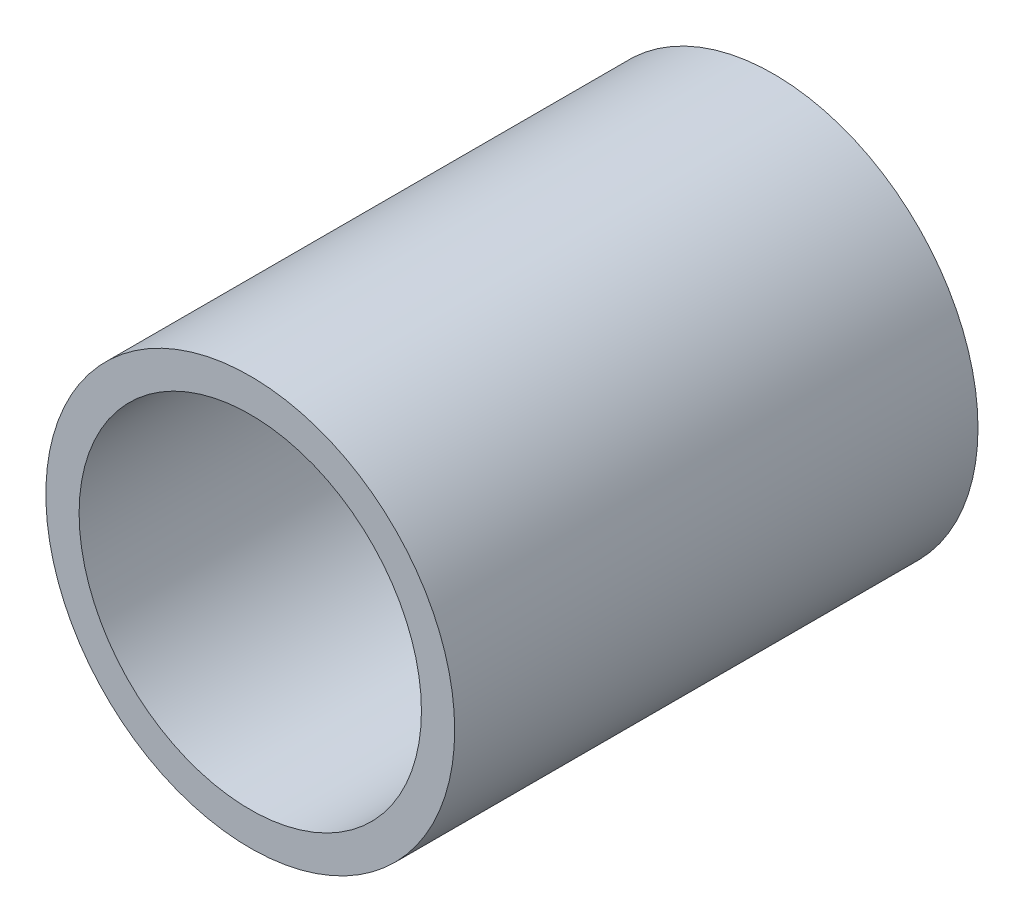
from build123d import *

# Parameters (mm, degrees)
SKETCH1_R      = 4.7625
SKETCH1_R_2    = 3.9878
EXTRUDE1_DEPTH = 12.192


with BuildPart() as part:
    # Sketch1 → Extrude1 (new body)
    with BuildSketch(Plane.XY):
        with Locations((-12.602978236, 4.568579611)):
            Circle(SKETCH1_R)
        with Locations((-12.602978236, 4.568579611)):
            Circle(SKETCH1_R_2, mode=Mode.SUBTRACT)
    extrude(amount=EXTRUDE1_DEPTH)


solid = part.part
